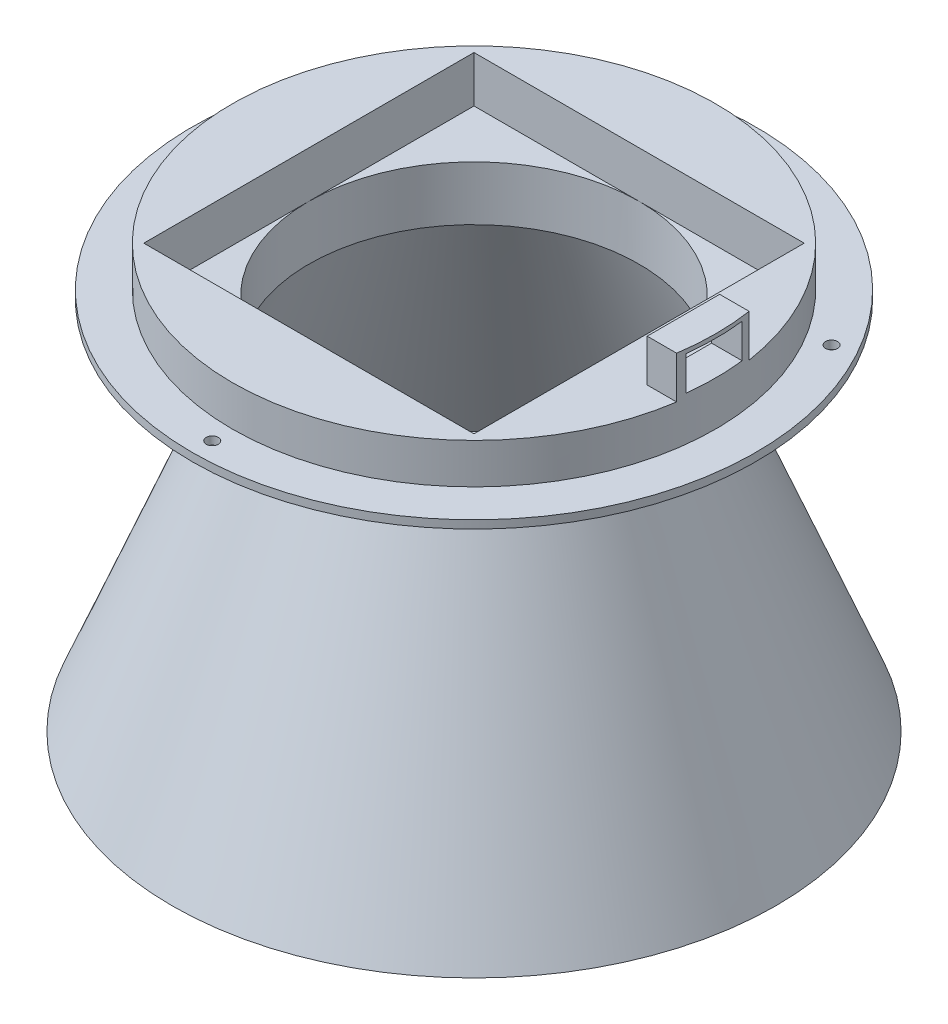
from build123d import *

# Parameters (mm, degrees)
CROQUIS2_W              = 82
CROQUIS2_H              = 82
CORTAR_EXTRUIR1_DEPTH   = 11.5
SALIENTE_EXTRUIR1_DEPTH = 10.5
CROQUIS4_W              = 14
CROQUIS4_H              = 8.5
CORTAR_EXTRUIR2_DEPTH   = 10.5
CROQUIS5_R              = 1.5
CORTAR_EXTRUIR3_DEPTH   = 10


with BuildPart() as part:
    # Croquis1 → Revolución1 (revolve)
    with BuildSketch(Plane.XY):
        Polygon((-67.901642817, 46.97611702), (-67.901642817, 61.97611702), (-67.901642817, 71.97611702), (-86.901642817, 71.97611702), (-86.901642817, 61.97611702), (-96.901642817, 61.97611702), (-96.901642817, 59.97611702), (-86.901642817, 59.97611702), (-69.901642817, 46.97611702), (-101.901642817, -33.02388298), (-99.901642817, -33.02388298), align=None)
    revolve(axis=Axis((-26.901642817, 46.97611702, 0), (0, -1, 0)))

    # Croquis2 → Cortar-Extruir1 (cut)
    with BuildSketch(Plane(origin=(0, 71.97611702, 0), x_dir=(1, 0, 0), z_dir=(0, 1, 0))):
        with Locations((-26.901642817, 0)):
            Rectangle(CROQUIS2_W, CROQUIS2_H)
    extrude(amount=-CORTAR_EXTRUIR1_DEPTH, mode=Mode.SUBTRACT)

    # Croquis3 → Saliente-Extruir1 (add)
    with BuildSketch(Plane(origin=(0, 71.97611702, 0), x_dir=(1, 0, 0), z_dir=(0, 1, 0))):
        with BuildLine():
            Line((32.419516983, 9), (25.098357183, 9))
            Line((25.098357183, 9), (25.098357183, -9))
            Line((25.098357183, -9), (32.419516983, -9))
            ThreePointArc((32.419516983, -9), (33.098357183, 0), (32.419516983, 9))
        make_face()
    extrude(amount=SALIENTE_EXTRUIR1_DEPTH)

    # Croquis4 → Cortar-Extruir2 (cut)
    with BuildSketch(Plane.ZY.offset(-25.098357183)):
        with Locations((0, 77.22611702)):
            Rectangle(CROQUIS4_W, CROQUIS4_H)
    extrude(amount=-CORTAR_EXTRUIR2_DEPTH, mode=Mode.SUBTRACT)

    # Croquis5 → Cortar-Extruir3 (cut)
    with BuildSketch(Plane(origin=(0, 61.97611702, 0), x_dir=(1, 0, 0), z_dir=(0, 1, 0))):
        with Locations((-26.901642817, -65)):
            Circle(CROQUIS5_R)
        with Locations((-83.193294063, 32.5)):
            Circle(CROQUIS5_R)
        with Locations((29.390008429, 32.5)):
            Circle(CROQUIS5_R)
    extrude(amount=-CORTAR_EXTRUIR3_DEPTH, mode=Mode.SUBTRACT)


solid = part.part
